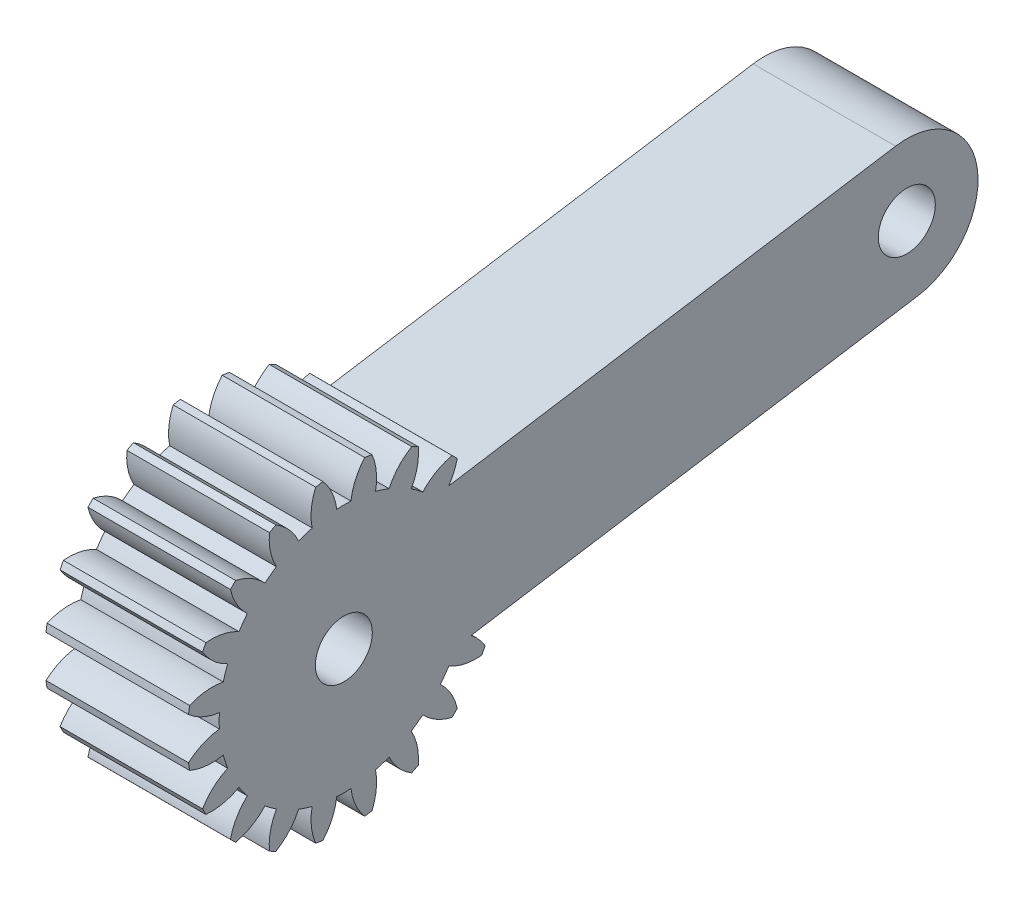
from build123d import *

# Parameters (mm, degrees)
BASPROSKE_W             = 10
BASPROSKE_H             = 11
TOOTHCUT_DEPTH          = 19.493242009
TEETHCUTS_COUNT         = 20
TEETHCUTS_ANGLE         = 342
BORSKE_R                = 0.4
BORE_DEPTH              = 50.0000508
CROQUIS1_R              = 2
SALIENTE_EXTRUIR1_DEPTH = 10
CROQUIS2_R              = 2
CORTAR_EXTRUIR1_DEPTH   = 10


with BuildPart() as part:
    # BasProSke → Base-Revolve (revolve)
    with BuildSketch(Plane(origin=(0, 0, 0), x_dir=(1, 0, 0), z_dir=(0, 1, 0)), mode=Mode.PRIVATE) as base_revolve_sk:
        with Locations((5, 5.5)):
            Rectangle(BASPROSKE_W, BASPROSKE_H)
    revolve(base_revolve_sk.sketch.rotate(Axis((-10, 0, 0), (1, 0, 0)), 180), axis=Axis((-10, 0, 0), (1, 0, 0)))

    # TooCutSke → ToothCut (cut, through all)
    with BuildSketch(Plane(origin=(0, 0, 0), x_dir=(0, 0, -1), z_dir=(1, 0, 0))):
        with BuildLine():
            ThreePointArc((0.499924007, 8.734705318), (0, 8.749), (-0.499924007, 8.734705318))
            ThreePointArc((-0.499924007, 8.734705318), (-0.824302243, 9.905497836), (-1.485192705, 10.924909509))
            ThreePointArc((-1.485192705, 10.924909509), (0, 11.0254), (1.485192705, 10.924909509))
            ThreePointArc((1.485192705, 10.924909509), (0.824302243, 9.905497836), (0.499924007, 8.734705318))
        make_face()
    toothcut = extrude(amount=TOOTHCUT_DEPTH, mode=Mode.SUBTRACT)

    # TeethCuts: ToothCut ×20 about axis
    teethcuts_axis = Axis((-10, 0, 0), (1, 0, 0))
    for i in range(1, TEETHCUTS_COUNT):
        add(toothcut.rotate(teethcuts_axis, i * TEETHCUTS_ANGLE / (TEETHCUTS_COUNT - 1)), mode=Mode.SUBTRACT)

    # BorSke → Bore (cut, symmetric)
    with BuildSketch(Plane(origin=(0, 0, 0), x_dir=(0, 0, -1), z_dir=(1, 0, 0))):
        with Locations(Location((0, 0, 0), (0, 0, 180))):
            Circle(BORSKE_R)
    extrude(amount=BORE_DEPTH, both=True, mode=Mode.SUBTRACT)

    # Croquis1 → Saliente-Extruir1 (add)
    with BuildSketch(Plane(origin=(10, 0, 0), x_dir=(0, 0, -1), z_dir=(1, 0, 0))):
        with BuildLine():
            Line((38.725361299, 11.195820305), (-0.782172325, 4.938441703))
            ThreePointArc((-0.782172325, 4.938441703), (-4.938441703, -0.782172325), (0.782172325, -4.938441703))
            Line((0.782172325, -4.938441703), (40.289705949, 1.318936899))
            ThreePointArc((40.289705949, 1.318936899), (44.445975327, 7.039550927), (38.725361299, 11.195820305))
        make_face()
        Circle(CROQUIS1_R, mode=Mode.SUBTRACT)
        with Locations((39.507533624, 6.257378602)):
            Circle(CROQUIS1_R, mode=Mode.SUBTRACT)
    extrude(amount=-SALIENTE_EXTRUIR1_DEPTH)

    # Croquis2 → Cortar-Extruir1 (cut)
    with BuildSketch(Plane(origin=(10, 0, 0), x_dir=(0, 0, -1), z_dir=(1, 0, 0))):
        Circle(CROQUIS2_R)
    extrude(amount=-CORTAR_EXTRUIR1_DEPTH, mode=Mode.SUBTRACT)


solid = part.part
